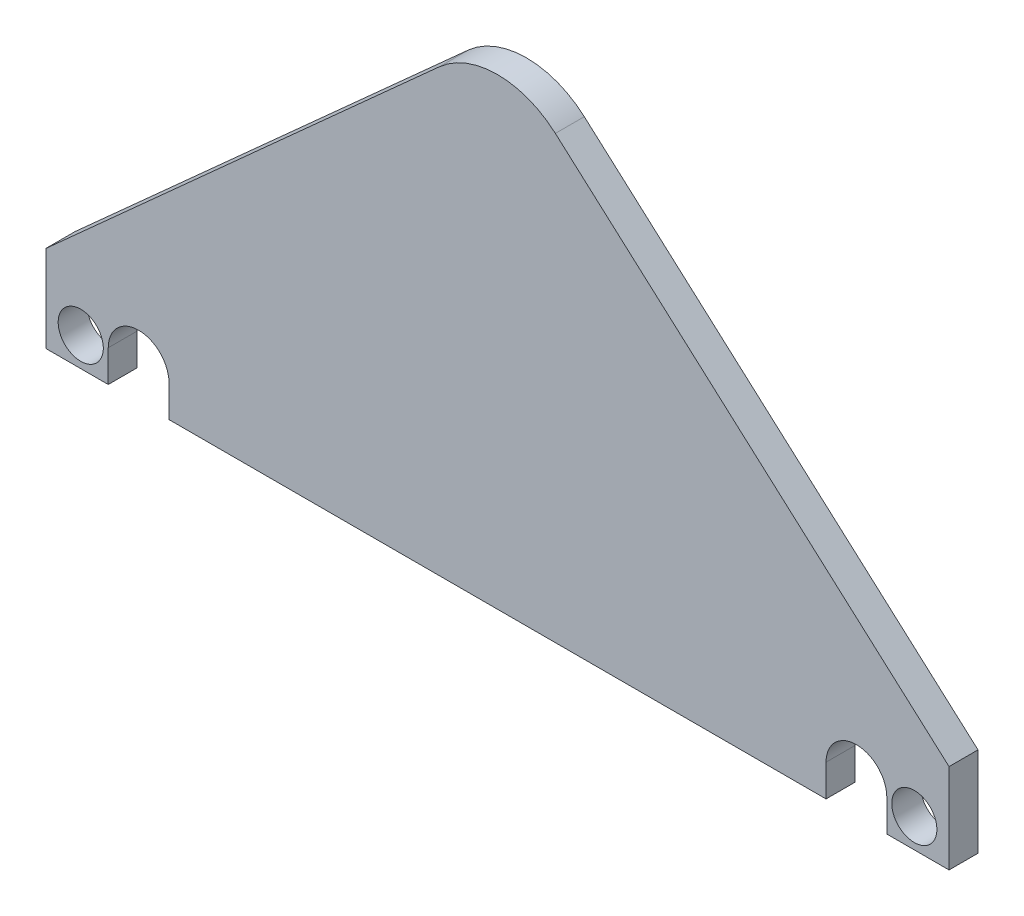
from build123d import *

# Parameters (mm, degrees)
SKETCH2_R           = 3.9
BOSS_EXTRUDE1_DEPTH = 5


with BuildPart() as part:
    # Sketch2 → Boss-Extrude1 (new body)
    with BuildSketch(Plane(origin=(0, 0, -1125.876159911), x_dir=(-1, 0, 0), z_dir=(0, 0, -1))):
        with BuildLine():
            Line((78, 17.5), (78, 32.5))
            Line((78, 32.5), (10.032697486, 93.651008078))
            ThreePointArc((10.032697486, 93.651008078), (0.028721986, 97.499972502), (-9.989920116, 93.689347438))
            Line((-9.989920116, 93.689347438), (-78, 32.969518252))
            Line((-78, 32.969518252), (-78, 17.5))
            Line((-78, 17.5), (-67.25, 17.5))
            Line((-67.25, 17.5), (-67.25, 23))
            ThreePointArc((-67.25, 23), (-62, 28.25), (-56.75, 23))
            Line((-56.75, 23), (-56.75, 17.5))
            Line((-56.75, 17.5), (56.75, 17.5))
            Line((56.75, 17.5), (56.75, 23))
            ThreePointArc((56.75, 23), (62, 28.25), (67.25, 23))
            Line((67.25, 23), (67.25, 17.5))
            Line((67.25, 17.5), (78, 17.5))
        make_face()
        with Locations((72, 22.5)):
            Circle(SKETCH2_R, mode=Mode.SUBTRACT)
        with Locations((-72, 22.5)):
            Circle(SKETCH2_R, mode=Mode.SUBTRACT)
    extrude(amount=BOSS_EXTRUDE1_DEPTH)


solid = part.part
